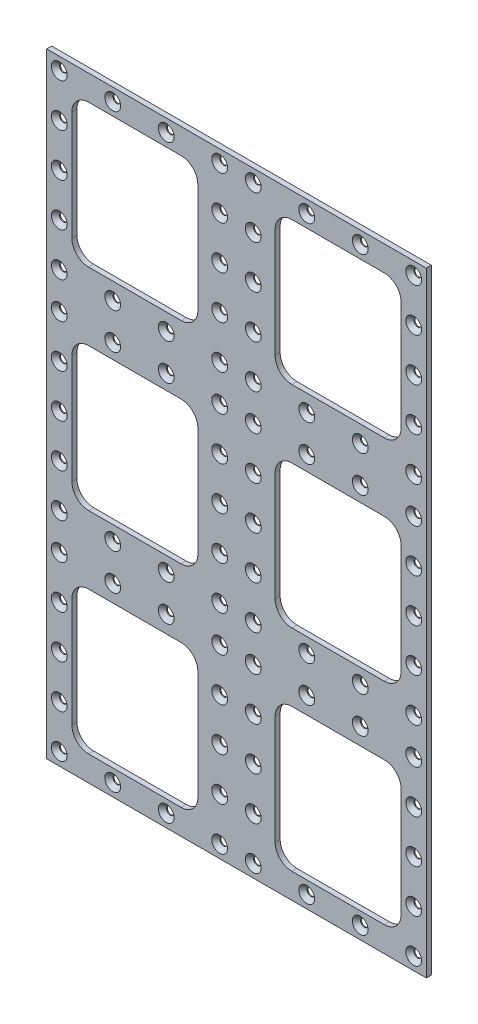
from build123d import *

# Parameters (mm, degrees)
SKETCH1_W              = 226
SKETCH1_H              = 366
BOSS_EXTRUDE1_DEPTH    = 3
SKETCH2_W              = 75
SKETCH2_H              = 85
CUT_EXTRUDE4_DEPTH     = 4
FILLET1_R              = 10
LPATTERN1_COUNT        = 3
LPATTERN1_PITCH        = 125.5
LPATTERN1_COUNT_DIR2   = 2
LPATTERN1_PITCH_DIR2   = 121
FILLET1_OF_LPATTERN1_R = 10
LPATTERN7_COUNT        = 4
LPATTERN7_PITCH        = 31.833333333
LPATTERN7_COUNT_DIR2   = 5
LPATTERN7_PITCH_DIR2   = 25.65625
LPATTERN8_COUNT        = 3
LPATTERN8_PITCH        = 124.1875


with BuildPart() as part:
    # Sketch1 → Boss-Extrude1 (new body)
    with BuildSketch(Plane.XY):
        Rectangle(SKETCH1_W, SKETCH1_H)
    extrude(amount=BOSS_EXTRUDE1_DEPTH)

    # Sketch2 → Cut-Extrude4 (cut, through all)
    with BuildSketch(Plane.XY):
        with Locations((-60.5, 125.5)):
            Rectangle(SKETCH2_W, SKETCH2_H)
    cut_extrude4 = extrude(amount=CUT_EXTRUDE4_DEPTH, mode=Mode.SUBTRACT)

    # Fillet1
    fillet1_edges = [part.edges().sort_by_distance(p)[0] for p in [
        (-23, 83, 1.5),
        (-23, 168, 1.5),
        (-98, 168, 1.5),
        (-98, 83, 1.5),
    ]]
    fillet(fillet1_edges, radius=FILLET1_R)

    # LPattern1: Cut-Extrude4 3 × 2
    with Locations(*[(j * LPATTERN1_PITCH_DIR2, -i * LPATTERN1_PITCH, 0) for i in range(LPATTERN1_COUNT) for j in range(LPATTERN1_COUNT_DIR2) if (i, j) != (0, 0)]):
        add(cut_extrude4, mode=Mode.SUBTRACT)

    # Fillet1 of LPattern1
    fillet1_of_lpattern1_edges = [part.edges().sort_by_distance(p)[0] for p in [
        (98, 83, 1.5),
        (98, 168, 1.5),
        (23, 168, 1.5),
        (23, 83, 1.5),
        (-23, -42.5, 1.5),
        (-23, 42.5, 1.5),
        (-98, 42.5, 1.5),
        (-98, -42.5, 1.5),
        (98, -42.5, 1.5),
        (98, 42.5, 1.5),
        (23, 42.5, 1.5),
        (23, -42.5, 1.5),
        (-23, -168, 1.5),
        (-23, -83, 1.5),
        (-98, -83, 1.5),
        (-98, -168, 1.5),
        (98, -168, 1.5),
        (98, -83, 1.5),
        (23, -83, 1.5),
        (23, -168, 1.5),
    ]]
    fillet(fillet1_of_lpattern1_edges, radius=FILLET1_OF_LPATTERN1_R)

    # Sketch13 → CSK for M4 Flat Head Machine Screw4 (revolve, cut)
    with BuildSketch(Plane(origin=(-105.5, 175.5, 3), x_dir=(0, -1, 0), z_dir=(1, 0, 0))):
        Polygon((0, 0), (0, 3), (2.25, 3), (2.25, 2.45), (4.7, 0), align=None)
    csk_for_m4_flat_head_machine_screw4 = revolve(axis=Axis((-105.5, 175.5, 9.35), (0, 0, -1)), mode=Mode.SUBTRACT)

    # LPattern7: CSK for M4 Flat Head Machine Screw4 4 × 5, 6 skipped
    with Locations(*[(i * LPATTERN7_PITCH, -j * LPATTERN7_PITCH_DIR2, 0) for i in range(LPATTERN7_COUNT) for j in range(LPATTERN7_COUNT_DIR2) if (i, j) not in ((0, 0), (1, 1), (1, 2), (1, 3), (2, 1), (2, 2), (2, 3))]):
        add(csk_for_m4_flat_head_machine_screw4, mode=Mode.SUBTRACT)

    # LPattern8: CSK for M4 Flat Head Machine Screw4 ×3
    with Locations(*[(0, -i * LPATTERN8_PITCH, 0) for i in range(1, LPATTERN8_COUNT)]):
        add(csk_for_m4_flat_head_machine_screw4, mode=Mode.SUBTRACT)

    # LPattern8 copy 1 sketch → LPattern8 copy 1 (revolve, cut)
    with BuildSketch(Plane(origin=(-105.5, 25.65625, 3), x_dir=(0, -1, 0), z_dir=(1, 0, 0))):
        Polygon((0, 0), (0, 3), (2.25, 3), (2.25, 2.45), (4.7, 0), align=None)
    revolve(axis=Axis((-105.5, 25.65625, 9.35), (0, 0, -1)), mode=Mode.SUBTRACT)

    # LPattern8 copy 2 sketch → LPattern8 copy 2 (revolve, cut)
    with BuildSketch(Plane(origin=(-105.5, -98.53125, 3), x_dir=(0, -1, 0), z_dir=(1, 0, 0))):
        Polygon((0, 0), (0, 3), (2.25, 3), (2.25, 2.45), (4.7, 0), align=None)
    revolve(axis=Axis((-105.5, -98.53125, 9.35), (0, 0, -1)), mode=Mode.SUBTRACT)

    # LPattern8 copy 3 sketch → LPattern8 copy 3 (revolve, cut)
    with BuildSketch(Plane(origin=(-105.5, 0, 3), x_dir=(0, -1, 0), z_dir=(1, 0, 0))):
        Polygon((0, 0), (0, 3), (2.25, 3), (2.25, 2.45), (4.7, 0), align=None)
    revolve(axis=Axis((-105.5, 0, 9.35), (0, 0, -1)), mode=Mode.SUBTRACT)

    # LPattern8 copy 4 sketch → LPattern8 copy 4 (revolve, cut)
    with BuildSketch(Plane(origin=(-105.5, -124.1875, 3), x_dir=(0, -1, 0), z_dir=(1, 0, 0))):
        Polygon((0, 0), (0, 3), (2.25, 3), (2.25, 2.45), (4.7, 0), align=None)
    revolve(axis=Axis((-105.5, -124.1875, 9.35), (0, 0, -1)), mode=Mode.SUBTRACT)

    # LPattern8 copy 5 sketch → LPattern8 copy 5 (revolve, cut)
    with BuildSketch(Plane(origin=(-105.5, -25.65625, 3), x_dir=(0, -1, 0), z_dir=(1, 0, 0))):
        Polygon((0, 0), (0, 3), (2.25, 3), (2.25, 2.45), (4.7, 0), align=None)
    revolve(axis=Axis((-105.5, -25.65625, 9.35), (0, 0, -1)), mode=Mode.SUBTRACT)

    # LPattern8 copy 6 sketch → LPattern8 copy 6 (revolve, cut)
    with BuildSketch(Plane(origin=(-105.5, -149.84375, 3), x_dir=(0, -1, 0), z_dir=(1, 0, 0))):
        Polygon((0, 0), (0, 3), (2.25, 3), (2.25, 2.45), (4.7, 0), align=None)
    revolve(axis=Axis((-105.5, -149.84375, 9.35), (0, 0, -1)), mode=Mode.SUBTRACT)

    # LPattern8 copy 7 sketch → LPattern8 copy 7 (revolve, cut)
    with BuildSketch(Plane(origin=(-105.5, -51.3125, 3), x_dir=(0, -1, 0), z_dir=(1, 0, 0))):
        Polygon((0, 0), (0, 3), (2.25, 3), (2.25, 2.45), (4.7, 0), align=None)
    revolve(axis=Axis((-105.5, -51.3125, 9.35), (0, 0, -1)), mode=Mode.SUBTRACT)

    # LPattern8 copy 8 sketch → LPattern8 copy 8 (revolve, cut)
    with BuildSketch(Plane(origin=(-105.5, -175.5, 3), x_dir=(0, -1, 0), z_dir=(1, 0, 0))):
        Polygon((0, 0), (0, 3), (2.25, 3), (2.25, 2.45), (4.7, 0), align=None)
    revolve(axis=Axis((-105.5, -175.5, 9.35), (0, 0, -1)), mode=Mode.SUBTRACT)

    # LPattern8 copy 9 sketch → LPattern8 copy 9 (revolve, cut)
    with BuildSketch(Plane(origin=(-73.666666667, 51.3125, 3), x_dir=(0, -1, 0), z_dir=(1, 0, 0))):
        Polygon((0, 0), (0, 3), (2.25, 3), (2.25, 2.45), (4.7, 0), align=None)
    revolve(axis=Axis((-73.666666667, 51.3125, 9.35), (0, 0, -1)), mode=Mode.SUBTRACT)

    # LPattern8 copy 10 sketch → LPattern8 copy 10 (revolve, cut)
    with BuildSketch(Plane(origin=(-73.666666667, -72.875, 3), x_dir=(0, -1, 0), z_dir=(1, 0, 0))):
        Polygon((0, 0), (0, 3), (2.25, 3), (2.25, 2.45), (4.7, 0), align=None)
    revolve(axis=Axis((-73.666666667, -72.875, 9.35), (0, 0, -1)), mode=Mode.SUBTRACT)

    # LPattern8 copy 11 sketch → LPattern8 copy 11 (revolve, cut)
    with BuildSketch(Plane(origin=(-73.666666667, -51.3125, 3), x_dir=(0, -1, 0), z_dir=(1, 0, 0))):
        Polygon((0, 0), (0, 3), (2.25, 3), (2.25, 2.45), (4.7, 0), align=None)
    revolve(axis=Axis((-73.666666667, -51.3125, 9.35), (0, 0, -1)), mode=Mode.SUBTRACT)

    # LPattern8 copy 12 sketch → LPattern8 copy 12 (revolve, cut)
    with BuildSketch(Plane(origin=(-73.666666667, -175.5, 3), x_dir=(0, -1, 0), z_dir=(1, 0, 0))):
        Polygon((0, 0), (0, 3), (2.25, 3), (2.25, 2.45), (4.7, 0), align=None)
    revolve(axis=Axis((-73.666666667, -175.5, 9.35), (0, 0, -1)), mode=Mode.SUBTRACT)

    # LPattern8 copy 13 sketch → LPattern8 copy 13 (revolve, cut)
    with BuildSketch(Plane(origin=(-41.833333333, 51.3125, 3), x_dir=(0, -1, 0), z_dir=(1, 0, 0))):
        Polygon((0, 0), (0, 3), (2.25, 3), (2.25, 2.45), (4.7, 0), align=None)
    revolve(axis=Axis((-41.833333333, 51.3125, 9.35), (0, 0, -1)), mode=Mode.SUBTRACT)

    # LPattern8 copy 14 sketch → LPattern8 copy 14 (revolve, cut)
    with BuildSketch(Plane(origin=(-41.833333333, -72.875, 3), x_dir=(0, -1, 0), z_dir=(1, 0, 0))):
        Polygon((0, 0), (0, 3), (2.25, 3), (2.25, 2.45), (4.7, 0), align=None)
    revolve(axis=Axis((-41.833333333, -72.875, 9.35), (0, 0, -1)), mode=Mode.SUBTRACT)

    # LPattern8 copy 15 sketch → LPattern8 copy 15 (revolve, cut)
    with BuildSketch(Plane(origin=(-41.833333333, -51.3125, 3), x_dir=(0, -1, 0), z_dir=(1, 0, 0))):
        Polygon((0, 0), (0, 3), (2.25, 3), (2.25, 2.45), (4.7, 0), align=None)
    revolve(axis=Axis((-41.833333333, -51.3125, 9.35), (0, 0, -1)), mode=Mode.SUBTRACT)

    # LPattern8 copy 16 sketch → LPattern8 copy 16 (revolve, cut)
    with BuildSketch(Plane(origin=(-41.833333333, -175.5, 3), x_dir=(0, -1, 0), z_dir=(1, 0, 0))):
        Polygon((0, 0), (0, 3), (2.25, 3), (2.25, 2.45), (4.7, 0), align=None)
    revolve(axis=Axis((-41.833333333, -175.5, 9.35), (0, 0, -1)), mode=Mode.SUBTRACT)

    # LPattern8 copy 17 sketch → LPattern8 copy 17 (revolve, cut)
    with BuildSketch(Plane(origin=(-10, 51.3125, 3), x_dir=(0, -1, 0), z_dir=(1, 0, 0))):
        Polygon((0, 0), (0, 3), (2.25, 3), (2.25, 2.45), (4.7, 0), align=None)
    revolve(axis=Axis((-10, 51.3125, 9.35), (0, 0, -1)), mode=Mode.SUBTRACT)

    # LPattern8 copy 18 sketch → LPattern8 copy 18 (revolve, cut)
    with BuildSketch(Plane(origin=(-10, -72.875, 3), x_dir=(0, -1, 0), z_dir=(1, 0, 0))):
        Polygon((0, 0), (0, 3), (2.25, 3), (2.25, 2.45), (4.7, 0), align=None)
    revolve(axis=Axis((-10, -72.875, 9.35), (0, 0, -1)), mode=Mode.SUBTRACT)

    # LPattern8 copy 19 sketch → LPattern8 copy 19 (revolve, cut)
    with BuildSketch(Plane(origin=(-10, 25.65625, 3), x_dir=(0, -1, 0), z_dir=(1, 0, 0))):
        Polygon((0, 0), (0, 3), (2.25, 3), (2.25, 2.45), (4.7, 0), align=None)
    revolve(axis=Axis((-10, 25.65625, 9.35), (0, 0, -1)), mode=Mode.SUBTRACT)

    # LPattern8 copy 20 sketch → LPattern8 copy 20 (revolve, cut)
    with BuildSketch(Plane(origin=(-10, -98.53125, 3), x_dir=(0, -1, 0), z_dir=(1, 0, 0))):
        Polygon((0, 0), (0, 3), (2.25, 3), (2.25, 2.45), (4.7, 0), align=None)
    revolve(axis=Axis((-10, -98.53125, 9.35), (0, 0, -1)), mode=Mode.SUBTRACT)

    # LPattern8 copy 21 sketch → LPattern8 copy 21 (revolve, cut)
    with BuildSketch(Plane(origin=(-10, 0, 3), x_dir=(0, -1, 0), z_dir=(1, 0, 0))):
        Polygon((0, 0), (0, 3), (2.25, 3), (2.25, 2.45), (4.7, 0), align=None)
    revolve(axis=Axis((-10, 0, 9.35), (0, 0, -1)), mode=Mode.SUBTRACT)

    # LPattern8 copy 22 sketch → LPattern8 copy 22 (revolve, cut)
    with BuildSketch(Plane(origin=(-10, -124.1875, 3), x_dir=(0, -1, 0), z_dir=(1, 0, 0))):
        Polygon((0, 0), (0, 3), (2.25, 3), (2.25, 2.45), (4.7, 0), align=None)
    revolve(axis=Axis((-10, -124.1875, 9.35), (0, 0, -1)), mode=Mode.SUBTRACT)

    # LPattern8 copy 23 sketch → LPattern8 copy 23 (revolve, cut)
    with BuildSketch(Plane(origin=(-10, -25.65625, 3), x_dir=(0, -1, 0), z_dir=(1, 0, 0))):
        Polygon((0, 0), (0, 3), (2.25, 3), (2.25, 2.45), (4.7, 0), align=None)
    revolve(axis=Axis((-10, -25.65625, 9.35), (0, 0, -1)), mode=Mode.SUBTRACT)

    # LPattern8 copy 24 sketch → LPattern8 copy 24 (revolve, cut)
    with BuildSketch(Plane(origin=(-10, -149.84375, 3), x_dir=(0, -1, 0), z_dir=(1, 0, 0))):
        Polygon((0, 0), (0, 3), (2.25, 3), (2.25, 2.45), (4.7, 0), align=None)
    revolve(axis=Axis((-10, -149.84375, 9.35), (0, 0, -1)), mode=Mode.SUBTRACT)

    # LPattern8 copy 25 sketch → LPattern8 copy 25 (revolve, cut)
    with BuildSketch(Plane(origin=(-10, -51.3125, 3), x_dir=(0, -1, 0), z_dir=(1, 0, 0))):
        Polygon((0, 0), (0, 3), (2.25, 3), (2.25, 2.45), (4.7, 0), align=None)
    revolve(axis=Axis((-10, -51.3125, 9.35), (0, 0, -1)), mode=Mode.SUBTRACT)

    # LPattern8 copy 26 sketch → LPattern8 copy 26 (revolve, cut)
    with BuildSketch(Plane(origin=(-10, -175.5, 3), x_dir=(0, -1, 0), z_dir=(1, 0, 0))):
        Polygon((0, 0), (0, 3), (2.25, 3), (2.25, 2.45), (4.7, 0), align=None)
    revolve(axis=Axis((-10, -175.5, 9.35), (0, 0, -1)), mode=Mode.SUBTRACT)

    # Mirror1: CSK for M4 Flat Head Machine Screw4 across plane
    add(csk_for_m4_flat_head_machine_screw4.mirror(Plane(origin=(0, 0, 0), x_dir=(0, 0, 1), z_dir=(1, 0, 0))), mode=Mode.SUBTRACT)

    # Mirror1 copy 1 sketch → Mirror1 copy 1 (revolve, cut)
    with BuildSketch(Plane(origin=(105.5, 51.3125, 3), x_dir=(0, -1, 0), z_dir=(-1, 0, 0))):
        Polygon((0, 0), (0, -3), (2.25, -3), (2.25, -2.45), (4.7, 0), align=None)
    revolve(axis=Axis((105.5, 51.3125, 9.35), (0, 0, 1)), mode=Mode.SUBTRACT)

    # Mirror1 copy 2 sketch → Mirror1 copy 2 (revolve, cut)
    with BuildSketch(Plane(origin=(105.5, -72.875, 3), x_dir=(0, -1, 0), z_dir=(-1, 0, 0))):
        Polygon((0, 0), (0, -3), (2.25, -3), (2.25, -2.45), (4.7, 0), align=None)
    revolve(axis=Axis((105.5, -72.875, 9.35), (0, 0, 1)), mode=Mode.SUBTRACT)

    # Mirror1 copy 3 sketch → Mirror1 copy 3 (revolve, cut)
    with BuildSketch(Plane(origin=(105.5, 25.65625, 3), x_dir=(0, -1, 0), z_dir=(-1, 0, 0))):
        Polygon((0, 0), (0, -3), (2.25, -3), (2.25, -2.45), (4.7, 0), align=None)
    revolve(axis=Axis((105.5, 25.65625, 9.35), (0, 0, 1)), mode=Mode.SUBTRACT)

    # Mirror1 copy 4 sketch → Mirror1 copy 4 (revolve, cut)
    with BuildSketch(Plane(origin=(105.5, -98.53125, 3), x_dir=(0, -1, 0), z_dir=(-1, 0, 0))):
        Polygon((0, 0), (0, -3), (2.25, -3), (2.25, -2.45), (4.7, 0), align=None)
    revolve(axis=Axis((105.5, -98.53125, 9.35), (0, 0, 1)), mode=Mode.SUBTRACT)

    # Mirror1 copy 5 sketch → Mirror1 copy 5 (revolve, cut)
    with BuildSketch(Plane(origin=(105.5, 0, 3), x_dir=(0, -1, 0), z_dir=(-1, 0, 0))):
        Polygon((0, 0), (0, -3), (2.25, -3), (2.25, -2.45), (4.7, 0), align=None)
    revolve(axis=Axis((105.5, 0, 9.35), (0, 0, 1)), mode=Mode.SUBTRACT)

    # Mirror1 copy 6 sketch → Mirror1 copy 6 (revolve, cut)
    with BuildSketch(Plane(origin=(105.5, -124.1875, 3), x_dir=(0, -1, 0), z_dir=(-1, 0, 0))):
        Polygon((0, 0), (0, -3), (2.25, -3), (2.25, -2.45), (4.7, 0), align=None)
    revolve(axis=Axis((105.5, -124.1875, 9.35), (0, 0, 1)), mode=Mode.SUBTRACT)

    # Mirror1 copy 7 sketch → Mirror1 copy 7 (revolve, cut)
    with BuildSketch(Plane(origin=(105.5, -25.65625, 3), x_dir=(0, -1, 0), z_dir=(-1, 0, 0))):
        Polygon((0, 0), (0, -3), (2.25, -3), (2.25, -2.45), (4.7, 0), align=None)
    revolve(axis=Axis((105.5, -25.65625, 9.35), (0, 0, 1)), mode=Mode.SUBTRACT)

    # Mirror1 copy 8 sketch → Mirror1 copy 8 (revolve, cut)
    with BuildSketch(Plane(origin=(105.5, -149.84375, 3), x_dir=(0, -1, 0), z_dir=(-1, 0, 0))):
        Polygon((0, 0), (0, -3), (2.25, -3), (2.25, -2.45), (4.7, 0), align=None)
    revolve(axis=Axis((105.5, -149.84375, 9.35), (0, 0, 1)), mode=Mode.SUBTRACT)

    # Mirror1 copy 9 sketch → Mirror1 copy 9 (revolve, cut)
    with BuildSketch(Plane(origin=(105.5, -51.3125, 3), x_dir=(0, -1, 0), z_dir=(-1, 0, 0))):
        Polygon((0, 0), (0, -3), (2.25, -3), (2.25, -2.45), (4.7, 0), align=None)
    revolve(axis=Axis((105.5, -51.3125, 9.35), (0, 0, 1)), mode=Mode.SUBTRACT)

    # Mirror1 copy 10 sketch → Mirror1 copy 10 (revolve, cut)
    with BuildSketch(Plane(origin=(105.5, -175.5, 3), x_dir=(0, -1, 0), z_dir=(-1, 0, 0))):
        Polygon((0, 0), (0, -3), (2.25, -3), (2.25, -2.45), (4.7, 0), align=None)
    revolve(axis=Axis((105.5, -175.5, 9.35), (0, 0, 1)), mode=Mode.SUBTRACT)

    # Mirror1 copy 11 sketch → Mirror1 copy 11 (revolve, cut)
    with BuildSketch(Plane(origin=(73.666666667, 51.3125, 3), x_dir=(0, -1, 0), z_dir=(-1, 0, 0))):
        Polygon((0, 0), (0, -3), (2.25, -3), (2.25, -2.45), (4.7, 0), align=None)
    revolve(axis=Axis((73.666666667, 51.3125, 9.35), (0, 0, 1)), mode=Mode.SUBTRACT)

    # Mirror1 copy 12 sketch → Mirror1 copy 12 (revolve, cut)
    with BuildSketch(Plane(origin=(73.666666667, -72.875, 3), x_dir=(0, -1, 0), z_dir=(-1, 0, 0))):
        Polygon((0, 0), (0, -3), (2.25, -3), (2.25, -2.45), (4.7, 0), align=None)
    revolve(axis=Axis((73.666666667, -72.875, 9.35), (0, 0, 1)), mode=Mode.SUBTRACT)

    # Mirror1 copy 13 sketch → Mirror1 copy 13 (revolve, cut)
    with BuildSketch(Plane(origin=(73.666666667, -51.3125, 3), x_dir=(0, -1, 0), z_dir=(-1, 0, 0))):
        Polygon((0, 0), (0, -3), (2.25, -3), (2.25, -2.45), (4.7, 0), align=None)
    revolve(axis=Axis((73.666666667, -51.3125, 9.35), (0, 0, 1)), mode=Mode.SUBTRACT)

    # Mirror1 copy 14 sketch → Mirror1 copy 14 (revolve, cut)
    with BuildSketch(Plane(origin=(73.666666667, -175.5, 3), x_dir=(0, -1, 0), z_dir=(-1, 0, 0))):
        Polygon((0, 0), (0, -3), (2.25, -3), (2.25, -2.45), (4.7, 0), align=None)
    revolve(axis=Axis((73.666666667, -175.5, 9.35), (0, 0, 1)), mode=Mode.SUBTRACT)

    # Mirror1 copy 15 sketch → Mirror1 copy 15 (revolve, cut)
    with BuildSketch(Plane(origin=(41.833333333, 51.3125, 3), x_dir=(0, -1, 0), z_dir=(-1, 0, 0))):
        Polygon((0, 0), (0, -3), (2.25, -3), (2.25, -2.45), (4.7, 0), align=None)
    revolve(axis=Axis((41.833333333, 51.3125, 9.35), (0, 0, 1)), mode=Mode.SUBTRACT)

    # Mirror1 copy 16 sketch → Mirror1 copy 16 (revolve, cut)
    with BuildSketch(Plane(origin=(41.833333333, -72.875, 3), x_dir=(0, -1, 0), z_dir=(-1, 0, 0))):
        Polygon((0, 0), (0, -3), (2.25, -3), (2.25, -2.45), (4.7, 0), align=None)
    revolve(axis=Axis((41.833333333, -72.875, 9.35), (0, 0, 1)), mode=Mode.SUBTRACT)

    # Mirror1 copy 17 sketch → Mirror1 copy 17 (revolve, cut)
    with BuildSketch(Plane(origin=(41.833333333, -51.3125, 3), x_dir=(0, -1, 0), z_dir=(-1, 0, 0))):
        Polygon((0, 0), (0, -3), (2.25, -3), (2.25, -2.45), (4.7, 0), align=None)
    revolve(axis=Axis((41.833333333, -51.3125, 9.35), (0, 0, 1)), mode=Mode.SUBTRACT)

    # Mirror1 copy 18 sketch → Mirror1 copy 18 (revolve, cut)
    with BuildSketch(Plane(origin=(41.833333333, -175.5, 3), x_dir=(0, -1, 0), z_dir=(-1, 0, 0))):
        Polygon((0, 0), (0, -3), (2.25, -3), (2.25, -2.45), (4.7, 0), align=None)
    revolve(axis=Axis((41.833333333, -175.5, 9.35), (0, 0, 1)), mode=Mode.SUBTRACT)

    # Mirror1 copy 19 sketch → Mirror1 copy 19 (revolve, cut)
    with BuildSketch(Plane(origin=(10, 51.3125, 3), x_dir=(0, -1, 0), z_dir=(-1, 0, 0))):
        Polygon((0, 0), (0, -3), (2.25, -3), (2.25, -2.45), (4.7, 0), align=None)
    revolve(axis=Axis((10, 51.3125, 9.35), (0, 0, 1)), mode=Mode.SUBTRACT)

    # Mirror1 copy 20 sketch → Mirror1 copy 20 (revolve, cut)
    with BuildSketch(Plane(origin=(10, -72.875, 3), x_dir=(0, -1, 0), z_dir=(-1, 0, 0))):
        Polygon((0, 0), (0, -3), (2.25, -3), (2.25, -2.45), (4.7, 0), align=None)
    revolve(axis=Axis((10, -72.875, 9.35), (0, 0, 1)), mode=Mode.SUBTRACT)

    # Mirror1 copy 21 sketch → Mirror1 copy 21 (revolve, cut)
    with BuildSketch(Plane(origin=(10, 25.65625, 3), x_dir=(0, -1, 0), z_dir=(-1, 0, 0))):
        Polygon((0, 0), (0, -3), (2.25, -3), (2.25, -2.45), (4.7, 0), align=None)
    revolve(axis=Axis((10, 25.65625, 9.35), (0, 0, 1)), mode=Mode.SUBTRACT)

    # Mirror1 copy 22 sketch → Mirror1 copy 22 (revolve, cut)
    with BuildSketch(Plane(origin=(10, -98.53125, 3), x_dir=(0, -1, 0), z_dir=(-1, 0, 0))):
        Polygon((0, 0), (0, -3), (2.25, -3), (2.25, -2.45), (4.7, 0), align=None)
    revolve(axis=Axis((10, -98.53125, 9.35), (0, 0, 1)), mode=Mode.SUBTRACT)

    # Mirror1 copy 23 sketch → Mirror1 copy 23 (revolve, cut)
    with BuildSketch(Plane(origin=(10, 0, 3), x_dir=(0, -1, 0), z_dir=(-1, 0, 0))):
        Polygon((0, 0), (0, -3), (2.25, -3), (2.25, -2.45), (4.7, 0), align=None)
    revolve(axis=Axis((10, 0, 9.35), (0, 0, 1)), mode=Mode.SUBTRACT)

    # Mirror1 copy 24 sketch → Mirror1 copy 24 (revolve, cut)
    with BuildSketch(Plane(origin=(10, -124.1875, 3), x_dir=(0, -1, 0), z_dir=(-1, 0, 0))):
        Polygon((0, 0), (0, -3), (2.25, -3), (2.25, -2.45), (4.7, 0), align=None)
    revolve(axis=Axis((10, -124.1875, 9.35), (0, 0, 1)), mode=Mode.SUBTRACT)

    # Mirror1 copy 25 sketch → Mirror1 copy 25 (revolve, cut)
    with BuildSketch(Plane(origin=(10, -25.65625, 3), x_dir=(0, -1, 0), z_dir=(-1, 0, 0))):
        Polygon((0, 0), (0, -3), (2.25, -3), (2.25, -2.45), (4.7, 0), align=None)
    revolve(axis=Axis((10, -25.65625, 9.35), (0, 0, 1)), mode=Mode.SUBTRACT)

    # Mirror1 copy 26 sketch → Mirror1 copy 26 (revolve, cut)
    with BuildSketch(Plane(origin=(10, -149.84375, 3), x_dir=(0, -1, 0), z_dir=(-1, 0, 0))):
        Polygon((0, 0), (0, -3), (2.25, -3), (2.25, -2.45), (4.7, 0), align=None)
    revolve(axis=Axis((10, -149.84375, 9.35), (0, 0, 1)), mode=Mode.SUBTRACT)

    # Mirror1 copy 27 sketch → Mirror1 copy 27 (revolve, cut)
    with BuildSketch(Plane(origin=(10, -51.3125, 3), x_dir=(0, -1, 0), z_dir=(-1, 0, 0))):
        Polygon((0, 0), (0, -3), (2.25, -3), (2.25, -2.45), (4.7, 0), align=None)
    revolve(axis=Axis((10, -51.3125, 9.35), (0, 0, 1)), mode=Mode.SUBTRACT)

    # Mirror1 copy 28 sketch → Mirror1 copy 28 (revolve, cut)
    with BuildSketch(Plane(origin=(10, -175.5, 3), x_dir=(0, -1, 0), z_dir=(-1, 0, 0))):
        Polygon((0, 0), (0, -3), (2.25, -3), (2.25, -2.45), (4.7, 0), align=None)
    revolve(axis=Axis((10, -175.5, 9.35), (0, 0, 1)), mode=Mode.SUBTRACT)

    # Mirror1 copy 29 sketch → Mirror1 copy 29 (revolve, cut)
    with BuildSketch(Plane(origin=(105.5, 149.84375, 3), x_dir=(0, -1, 0), z_dir=(-1, 0, 0))):
        Polygon((0, 0), (0, -3), (2.25, -3), (2.25, -2.45), (4.7, 0), align=None)
    revolve(axis=Axis((105.5, 149.84375, 9.35), (0, 0, 1)), mode=Mode.SUBTRACT)

    # Mirror1 copy 30 sketch → Mirror1 copy 30 (revolve, cut)
    with BuildSketch(Plane(origin=(105.5, 124.1875, 3), x_dir=(0, -1, 0), z_dir=(-1, 0, 0))):
        Polygon((0, 0), (0, -3), (2.25, -3), (2.25, -2.45), (4.7, 0), align=None)
    revolve(axis=Axis((105.5, 124.1875, 9.35), (0, 0, 1)), mode=Mode.SUBTRACT)

    # Mirror1 copy 31 sketch → Mirror1 copy 31 (revolve, cut)
    with BuildSketch(Plane(origin=(105.5, 98.53125, 3), x_dir=(0, -1, 0), z_dir=(-1, 0, 0))):
        Polygon((0, 0), (0, -3), (2.25, -3), (2.25, -2.45), (4.7, 0), align=None)
    revolve(axis=Axis((105.5, 98.53125, 9.35), (0, 0, 1)), mode=Mode.SUBTRACT)

    # Mirror1 copy 32 sketch → Mirror1 copy 32 (revolve, cut)
    with BuildSketch(Plane(origin=(105.5, 72.875, 3), x_dir=(0, -1, 0), z_dir=(-1, 0, 0))):
        Polygon((0, 0), (0, -3), (2.25, -3), (2.25, -2.45), (4.7, 0), align=None)
    revolve(axis=Axis((105.5, 72.875, 9.35), (0, 0, 1)), mode=Mode.SUBTRACT)

    # Mirror1 copy 33 sketch → Mirror1 copy 33 (revolve, cut)
    with BuildSketch(Plane(origin=(73.666666667, 175.5, 3), x_dir=(0, -1, 0), z_dir=(-1, 0, 0))):
        Polygon((0, 0), (0, -3), (2.25, -3), (2.25, -2.45), (4.7, 0), align=None)
    revolve(axis=Axis((73.666666667, 175.5, 9.35), (0, 0, 1)), mode=Mode.SUBTRACT)

    # Mirror1 copy 34 sketch → Mirror1 copy 34 (revolve, cut)
    with BuildSketch(Plane(origin=(73.666666667, 72.875, 3), x_dir=(0, -1, 0), z_dir=(-1, 0, 0))):
        Polygon((0, 0), (0, -3), (2.25, -3), (2.25, -2.45), (4.7, 0), align=None)
    revolve(axis=Axis((73.666666667, 72.875, 9.35), (0, 0, 1)), mode=Mode.SUBTRACT)

    # Mirror1 copy 35 sketch → Mirror1 copy 35 (revolve, cut)
    with BuildSketch(Plane(origin=(41.833333333, 175.5, 3), x_dir=(0, -1, 0), z_dir=(-1, 0, 0))):
        Polygon((0, 0), (0, -3), (2.25, -3), (2.25, -2.45), (4.7, 0), align=None)
    revolve(axis=Axis((41.833333333, 175.5, 9.35), (0, 0, 1)), mode=Mode.SUBTRACT)

    # Mirror1 copy 36 sketch → Mirror1 copy 36 (revolve, cut)
    with BuildSketch(Plane(origin=(41.833333333, 72.875, 3), x_dir=(0, -1, 0), z_dir=(-1, 0, 0))):
        Polygon((0, 0), (0, -3), (2.25, -3), (2.25, -2.45), (4.7, 0), align=None)
    revolve(axis=Axis((41.833333333, 72.875, 9.35), (0, 0, 1)), mode=Mode.SUBTRACT)

    # Mirror1 copy 37 sketch → Mirror1 copy 37 (revolve, cut)
    with BuildSketch(Plane(origin=(10, 175.5, 3), x_dir=(0, -1, 0), z_dir=(-1, 0, 0))):
        Polygon((0, 0), (0, -3), (2.25, -3), (2.25, -2.45), (4.7, 0), align=None)
    revolve(axis=Axis((10, 175.5, 9.35), (0, 0, 1)), mode=Mode.SUBTRACT)

    # Mirror1 copy 38 sketch → Mirror1 copy 38 (revolve, cut)
    with BuildSketch(Plane(origin=(10, 149.84375, 3), x_dir=(0, -1, 0), z_dir=(-1, 0, 0))):
        Polygon((0, 0), (0, -3), (2.25, -3), (2.25, -2.45), (4.7, 0), align=None)
    revolve(axis=Axis((10, 149.84375, 9.35), (0, 0, 1)), mode=Mode.SUBTRACT)

    # Mirror1 copy 39 sketch → Mirror1 copy 39 (revolve, cut)
    with BuildSketch(Plane(origin=(10, 124.1875, 3), x_dir=(0, -1, 0), z_dir=(-1, 0, 0))):
        Polygon((0, 0), (0, -3), (2.25, -3), (2.25, -2.45), (4.7, 0), align=None)
    revolve(axis=Axis((10, 124.1875, 9.35), (0, 0, 1)), mode=Mode.SUBTRACT)

    # Mirror1 copy 40 sketch → Mirror1 copy 40 (revolve, cut)
    with BuildSketch(Plane(origin=(10, 98.53125, 3), x_dir=(0, -1, 0), z_dir=(-1, 0, 0))):
        Polygon((0, 0), (0, -3), (2.25, -3), (2.25, -2.45), (4.7, 0), align=None)
    revolve(axis=Axis((10, 98.53125, 9.35), (0, 0, 1)), mode=Mode.SUBTRACT)

    # Mirror1 copy 41 sketch → Mirror1 copy 41 (revolve, cut)
    with BuildSketch(Plane(origin=(10, 72.875, 3), x_dir=(0, -1, 0), z_dir=(-1, 0, 0))):
        Polygon((0, 0), (0, -3), (2.25, -3), (2.25, -2.45), (4.7, 0), align=None)
    revolve(axis=Axis((10, 72.875, 9.35), (0, 0, 1)), mode=Mode.SUBTRACT)


solid = part.part
